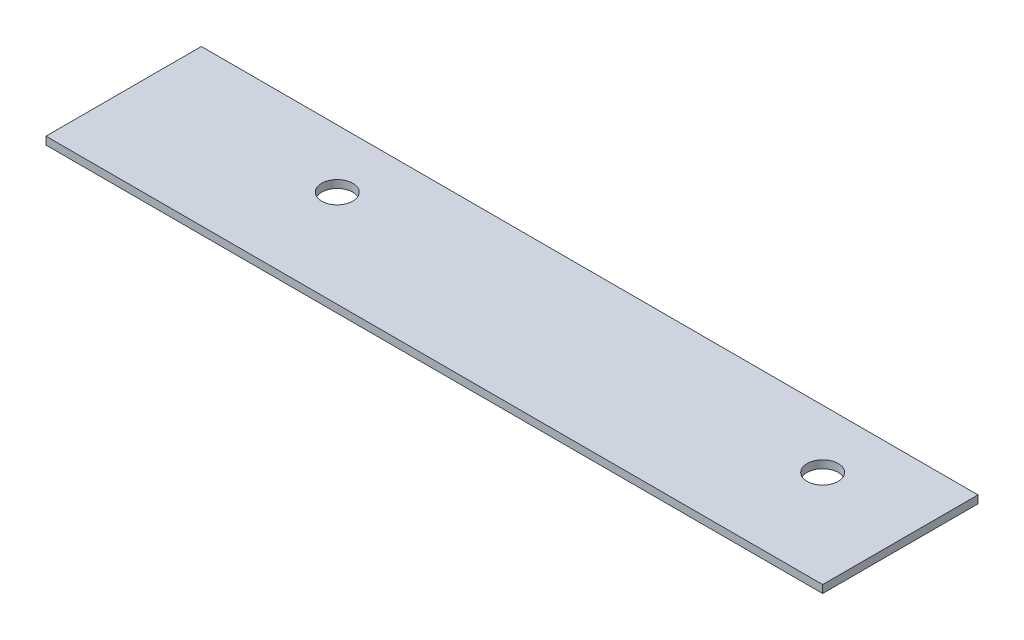
from build123d import *

# Parameters (mm, degrees)
SKETCH1_W           = 80
SKETCH1_H           = 16
SKETCH1_R           = 1.6
BOSS_EXTRUDE1_DEPTH = 0.8


with BuildPart() as part:
    # Sketch1 → Boss-Extrude1 (new body)
    with BuildSketch(Plane(origin=(0, 0, 0), x_dir=(1, 0, 0), z_dir=(0, 1, 0))):
        with Locations((40, 8)):
            Rectangle(SKETCH1_W, SKETCH1_H)
        with Locations((20, 10)):
            Circle(SKETCH1_R, mode=Mode.SUBTRACT)
        with Locations((70, 10)):
            Circle(SKETCH1_R, mode=Mode.SUBTRACT)
    extrude(amount=BOSS_EXTRUDE1_DEPTH)


solid = part.part
